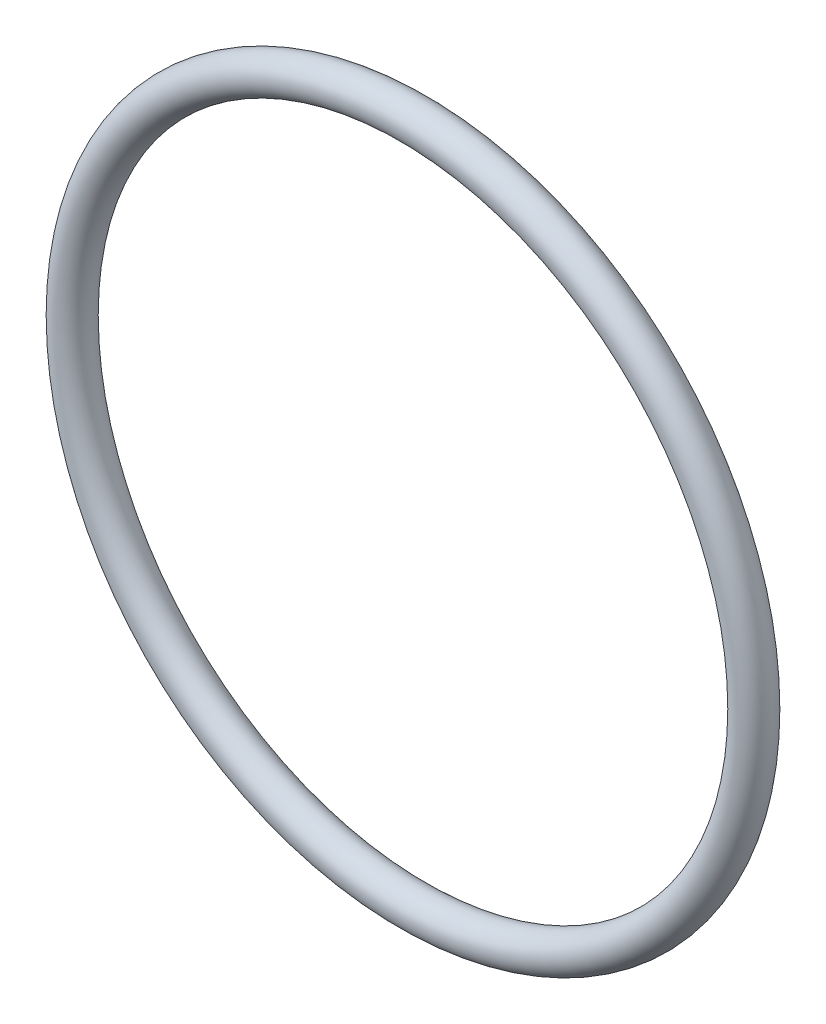
from build123d import *

# Parameters (mm, degrees)
SKETCH1_R = 1


with BuildPart() as part:
    # Sketch1 → Revolve1 (revolve)
    with BuildSketch(Plane(origin=(0, 0, 0), x_dir=(0, 0, -1), z_dir=(1, 0, 0))):
        with Locations((0, 18.5)):
            Circle(SKETCH1_R)
    revolve(axis=Axis((0, 0, 1.694046819), (0, 0, -1)))


solid = part.part
